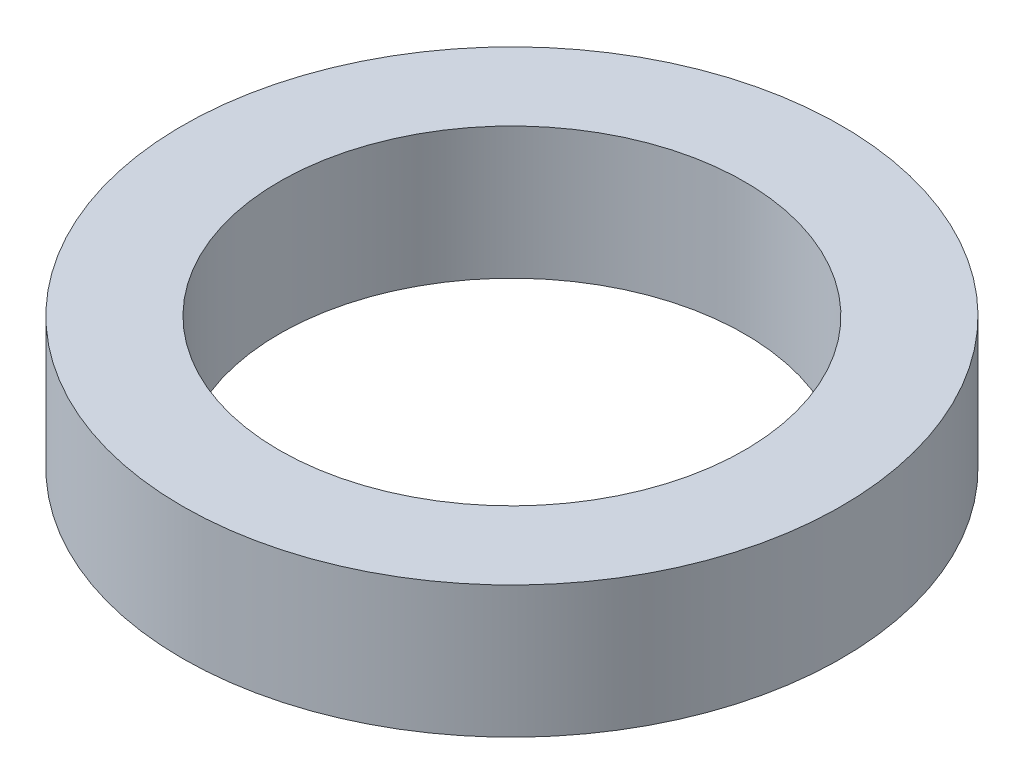
from build123d import *

# Parameters (mm, degrees)
SKETCH_2_R      = 42.5
SKETCH_2_R_2    = 30
EXTRUDE_1_DEPTH = 17


with BuildPart() as part:
    # 草图2 → 凸台-拉伸1 (new body)
    with BuildSketch(Plane(origin=(0, 0, 0), x_dir=(1, 0, 0), z_dir=(0, 1, 0))):
        Circle(SKETCH_2_R)
        Circle(SKETCH_2_R_2, mode=Mode.SUBTRACT)
    extrude(amount=EXTRUDE_1_DEPTH)


solid = part.part
